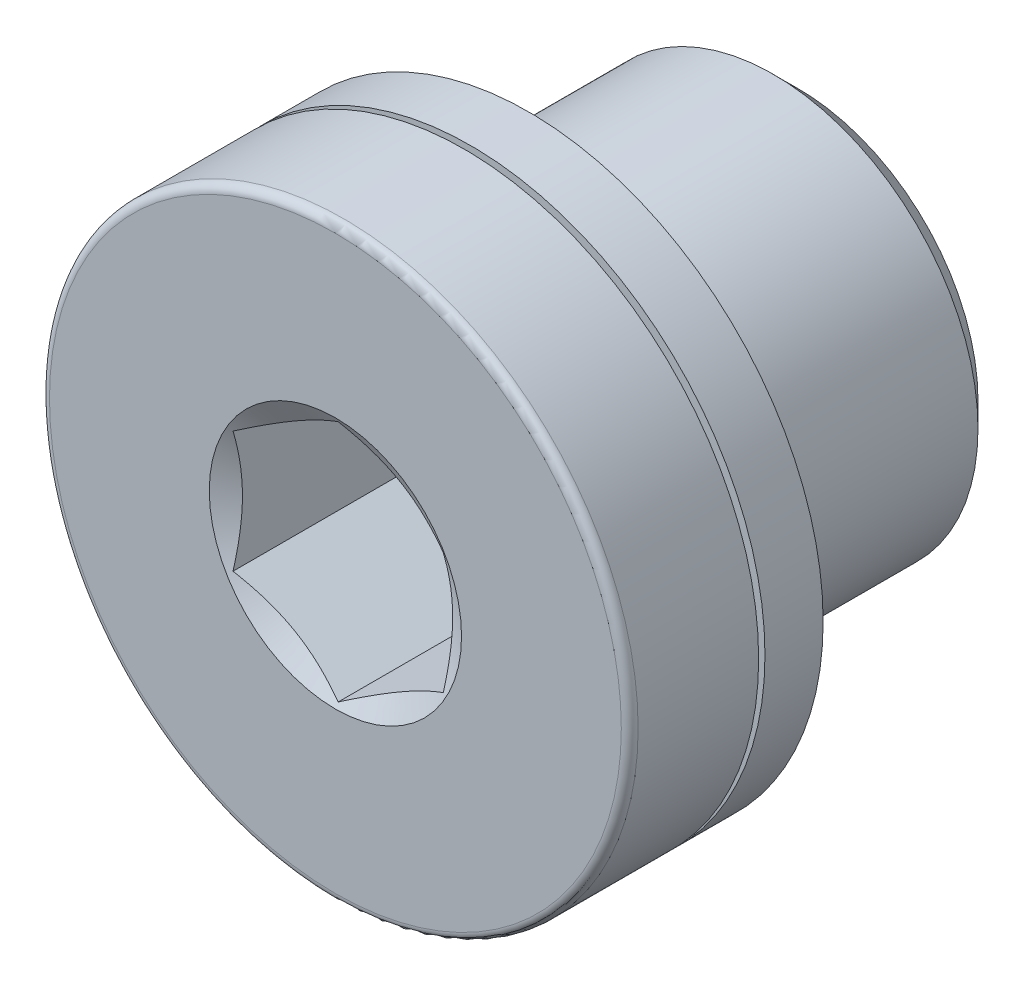
from build123d import *

# Parameters (mm, degrees)
CUT_EXTRUDE1_DEPTH = 4.6


with BuildPart() as part:
    # Sketch1 → Revolve1 (revolve)
    with BuildSketch(Plane(origin=(0, 0, 0), x_dir=(0, 0, -1), z_dir=(1, 0, 0))):
        with BuildLine():
            Line((-2.867949192, 0), (-4.6, 3))
            Line((-4.6, 3), (-4.6, 6.8))
            ThreePointArc((-4.6, 6.8), (-4.541421356, 6.941421356), (-4.4, 7))
            Line((-4.4, 7), (-1.533333333, 7))
            Line((-1.533333333, 7), (-1.533333333, 6.3))
            Line((-1.533333333, 6.3), (-1.383333333, 6.3))
            Line((-1.383333333, 6.3), (-1.383333333, 7))
            Line((-1.383333333, 7), (0, 7))
            Line((0, 7), (0, 4.283))
            Line((0, 4.283), (0.581, 4.864))
            Line((0.581, 4.864), (5.819, 4.864))
            Line((5.819, 4.864), (6.4, 4.283))
            Line((6.4, 4.283), (6.4, 0))
            Line((6.4, 0), (-2.867949192, 0))
        make_face()
    revolve(axis=Axis((0, 0, -6.4), (0, 0, 1)))

    # Sketch2 → Cut-Extrude1 (cut)
    with BuildSketch(Plane.XY.offset(4.6)):
        Polygon((-2.5, -1.443375673), (0, -2.886751346), (2.5, -1.443375673), (2.5, 1.443375673), (0, 2.886751346), (-2.5, 1.443375673), align=None)
    extrude(amount=-CUT_EXTRUDE1_DEPTH, mode=Mode.SUBTRACT)


solid = part.part
